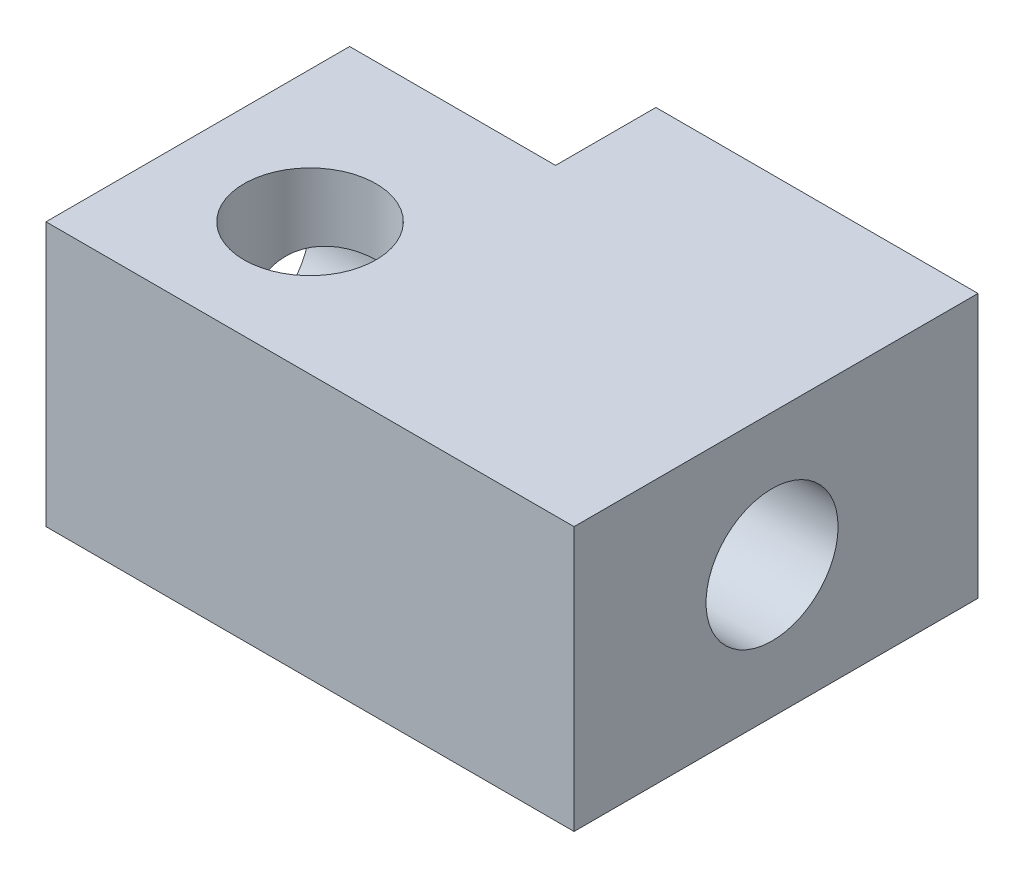
from build123d import *

# Parameters (mm, degrees)
SKETCH4_R           = 1.25
BOSS_EXTRUDE2_DEPTH = 5
CUT_EXTRUDE2_DEPTH  = 10


with BuildPart() as part:
    # Sketch4 → Boss-Extrude2 (new body)
    with BuildSketch(Plane(origin=(0, 0, 0), x_dir=(1, 0, 0), z_dir=(0, 1, 0))):
        Polygon((82.9, -82.75), (79, -82.75), (79, -86), (79, -88.5), (89, -88.5), (89, -80.85), (82.9, -80.85), align=None)
        with Locations((81.5, -86)):
            Circle(SKETCH4_R, mode=Mode.SUBTRACT)
    extrude(amount=BOSS_EXTRUDE2_DEPTH)

    # Sketch5 → Cut-Extrude2 (cut)
    with BuildSketch(Plane(origin=(89, 0, 0), x_dir=(0, 0, -1), z_dir=(1, 0, 0))):
        with BuildLine():
            ThreePointArc((-84.75, 3.75), (-86, 2.5), (-84.75, 1.25))
            Line((-84.75, 1.25), (-84.75, 3.75))
        make_face()
        with BuildLine():
            Line((-84.75, 3.75), (-84.75, 1.25))
            ThreePointArc((-84.75, 1.25), (-83.866116524, 1.616116524), (-83.5, 2.5))
            ThreePointArc((-83.5, 2.5), (-83.866116524, 3.383883476), (-84.75, 3.75))
        make_face()
    extrude(amount=-CUT_EXTRUDE2_DEPTH, mode=Mode.SUBTRACT)


solid = part.part
